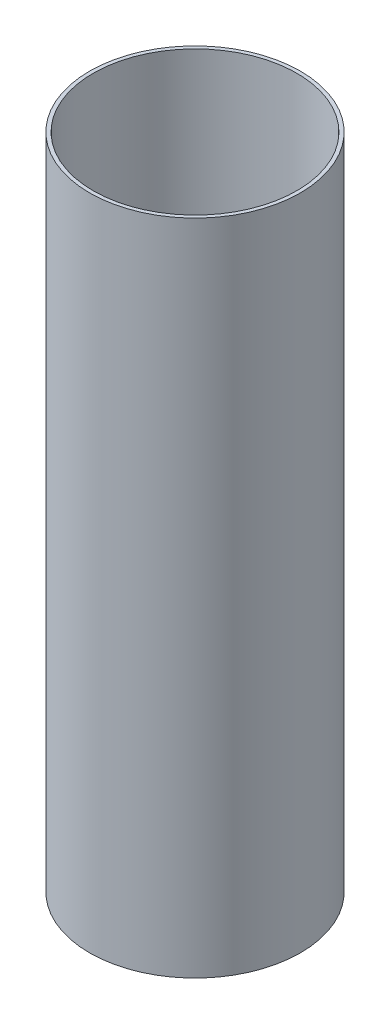
from build123d import *

# Parameters (mm, degrees)
SKETCH1_R           = 92.075
SKETCH1_R_2         = 88.9
BOSS_EXTRUDE1_DEPTH = 574.675


with BuildPart() as part:
    # Sketch1 → Boss-Extrude1 (new body)
    with BuildSketch(Plane(origin=(0, 0, 0), x_dir=(1, 0, 0), z_dir=(0, 1, 0))):
        Circle(SKETCH1_R)
        Circle(SKETCH1_R_2, mode=Mode.SUBTRACT)
    extrude(amount=BOSS_EXTRUDE1_DEPTH)


solid = part.part
